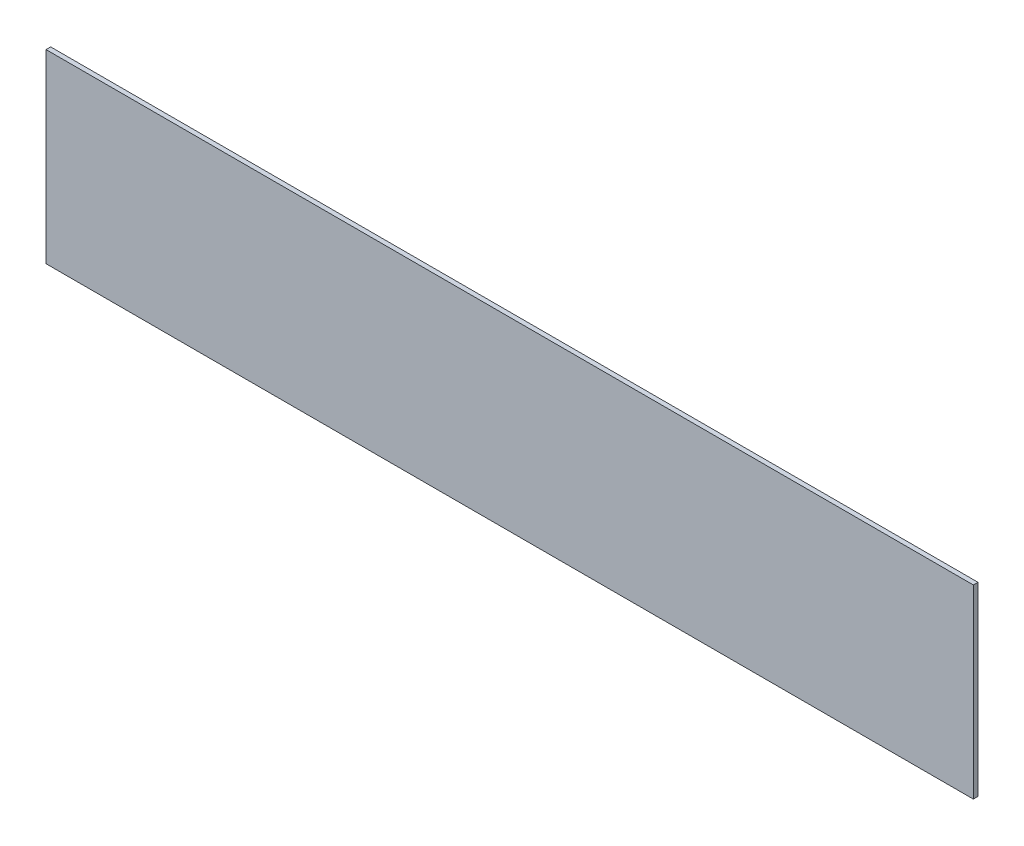
from build123d import *

# Parameters (mm, degrees)
SKETCH1_W           = 300
SKETCH1_H           = 60
BOSS_EXTRUDE1_DEPTH = 1.5


with BuildPart() as part:
    # Sketch1 → Boss-Extrude1 (new body)
    with BuildSketch(Plane.XY):
        with Locations((95.078740157, -0.885826772)):
            Rectangle(SKETCH1_W, SKETCH1_H)
    extrude(amount=BOSS_EXTRUDE1_DEPTH)


solid = part.part
